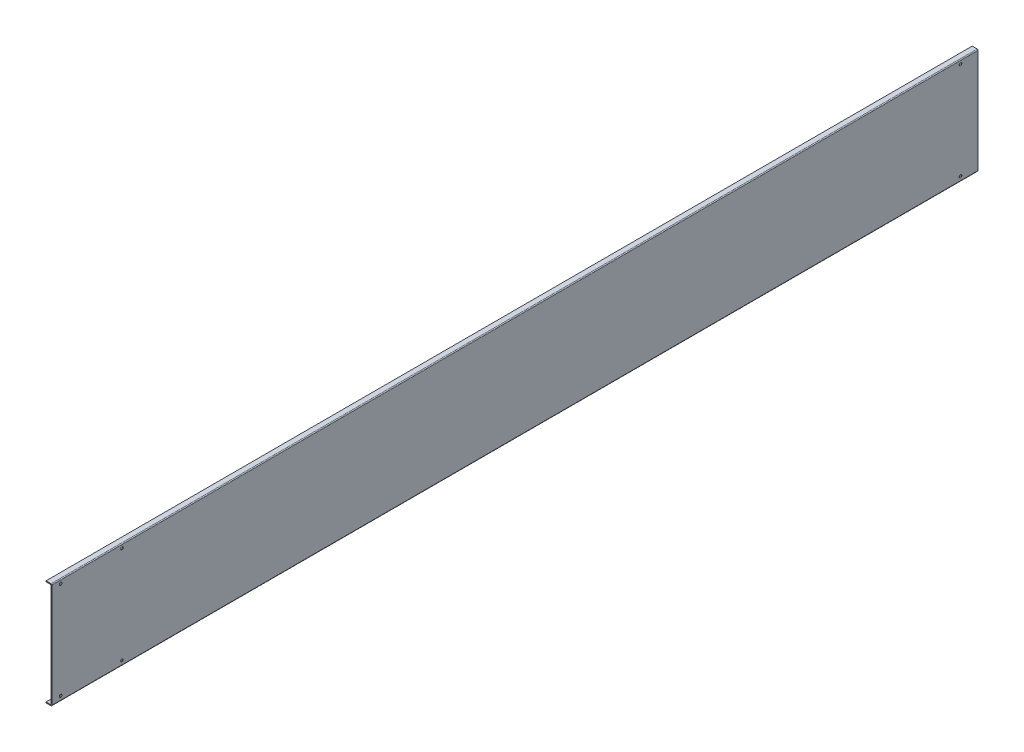
from build123d import *

# Parameters (mm, degrees)
BOSS_EXTRUDE1_DEPTH            = 1585
FILLET1_R                      = 1.5
F_4_5_4_5_DIAMETER_HOLE1_D     = 4.5
F_4_5_4_5_DIAMETER_HOLE1_DEPTH = 1.5
LPATTERN2_COUNT                = 2
LPATTERN2_PITCH                = 166


with BuildPart() as part:
    # Sketch1 → Boss-Extrude1 (new body)
    with BuildSketch(Plane.XY):
        Polygon((-10, -1.5), (-10, 0), (0, 0), (0, -181), (-10, -181), (-10, -179.5), (-1.5, -179.5), (-1.5, -1.5), align=None)
    extrude(amount=-BOSS_EXTRUDE1_DEPTH)

    # Fillet1
    fillet1_edges = [part.edges().sort_by_distance(p)[0] for p in [
        (0, -181, -792.5),
        (0, 0, -792.5),
    ]]
    fillet(fillet1_edges, radius=FILLET1_R)

    # Ø4.5 (4.5) Diameter Hole1
    with Locations(Plane(origin=(0, 0, 0), x_dir=(0, 0, -1), z_dir=(1, 0, 0))):
        with Locations((15, -7), (120, -7), (1555, -7)):
            f_4_5_4_5_diameter_hole1 = Hole(F_4_5_4_5_DIAMETER_HOLE1_D / 2, depth=F_4_5_4_5_DIAMETER_HOLE1_DEPTH)

    # LPattern2: Ø4.5 (4.5) Diameter Hole1 ×2
    with Locations(*[(0, -i * LPATTERN2_PITCH, 0) for i in range(1, LPATTERN2_COUNT)]):
        add(f_4_5_4_5_diameter_hole1, mode=Mode.SUBTRACT)


solid = part.part
